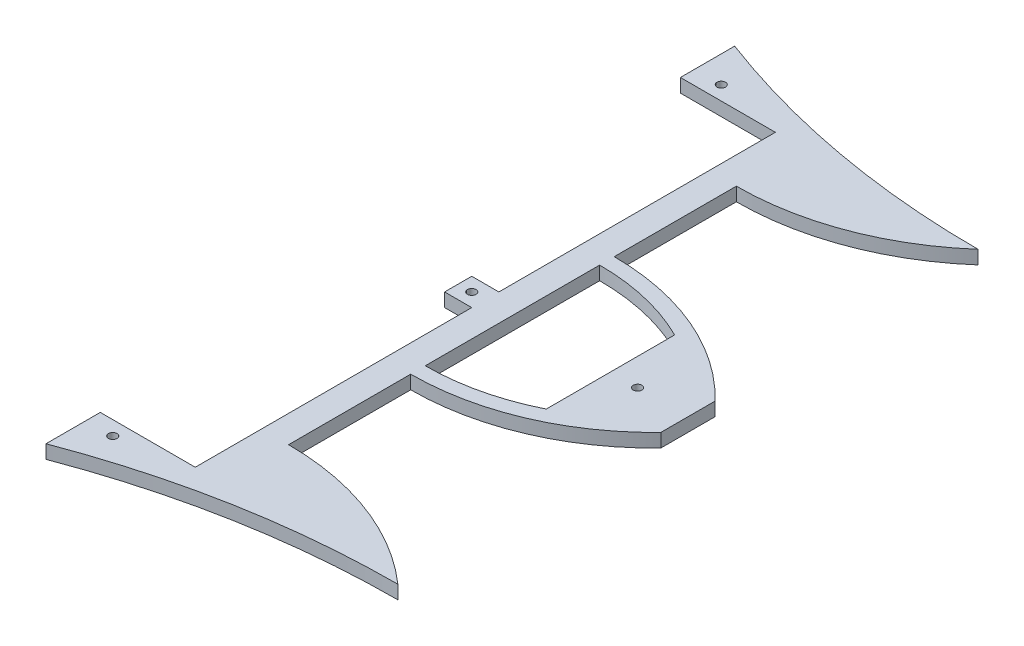
from build123d import *

# Parameters (mm, degrees)
BOSS_EXTRUDE3_DEPTH = 6.35
SKETCH2_R           = 2
CUT_EXTRUDE1_DEPTH  = 6.35
SKETCH3_W           = 44.45
SKETCH3_H           = 34.144934764
CUT_EXTRUDE2_DEPTH  = 6.35
BOSS_EXTRUDE5_DEPTH = 6.35
CUT_EXTRUDE3_DEPTH  = 6.35
CUT_EXTRUDE4_DEPTH  = 6.35
SKETCH8_R           = 2
CUT_EXTRUDE5_DEPTH  = 6.35


with BuildPart() as part:
    # Sketch1 → Boss-Extrude3 (new body)
    with BuildSketch(Plane(origin=(0, 0, 0), x_dir=(1, 0, 0), z_dir=(0, 1, 0))):
        with BuildLine():
            ThreePointArc((101.6, -161.144934764), (118.310930869, -149.307647617), (133.654639598, -135.744934764))
            Line((133.654639598, -135.744934764), (124.436872293, -135.744934764))
            Line((124.436872293, -135.744934764), (101.6, -135.744934764))
            Line((101.6, -135.744934764), (101.6, -161.144934764))
        make_face()
        with BuildLine():
            Line((146.05, -112.163363002), (146.05, -101.6))
            Line((146.05, -101.6), (101.6, -101.6))
            Line((101.6, -101.6), (101.6, -135.744934764))
            Line((101.6, -135.744934764), (124.436872293, -135.744934764))
            ThreePointArc((124.436872293, -135.744934764), (135.756435031, -124.424325787), (146.05, -112.163363002))
        make_face()
        with BuildLine():
            Line((152.4, -76.2), (152.4, -101.6))
            Line((152.4, -101.6), (157.687433266, -106.887433266))
            ThreePointArc((157.687433266, -106.887433266), (155.08800922, -110.62531083), (152.4, -114.3))
            ThreePointArc((152.4, -114.3), (143.428677452, -125.373300524), (133.654639598, -135.744934764))
            Line((133.654639598, -135.744934764), (190.5, -135.744934764))
            Line((190.5, -135.744934764), (240.876195248, -135.744934764))
            ThreePointArc((240.876195248, -135.744934764), (203.220744642, -110.47631512), (158.75, -101.6))
            Line((158.75, -101.6), (158.75, -76.2))
            Line((158.75, -76.2), (152.4, -76.2))
        make_face()
        with BuildLine():
            Line((146.05, -76.2), (152.4, -76.2))
            Line((152.4, -76.2), (152.4, -50.8))
            Line((152.4, -50.8), (190.076195248, -12.7))
            ThreePointArc((190.076195248, -12.7), (190.5, 0), (190.076195248, 12.7))
            Line((190.076195248, 12.7), (152.4, 50.8))
            Line((152.4, 50.8), (152.4, 76.2))
            Line((152.4, 76.2), (146.05, 76.2))
            Line((146.05, 76.2), (146.05, 6.35))
            Line((146.05, 6.35), (133.35, 6.35))
            Line((133.35, 6.35), (133.35, -6.35))
            Line((133.35, -6.35), (146.05, -6.35))
            Line((146.05, -6.35), (146.05, -76.2))
        make_face()
        with BuildLine():
            Line((157.687433266, -106.887433266), (152.4, -101.6))
            Line((152.4, -101.6), (152.4, -76.2))
            Line((152.4, -76.2), (146.05, -76.2))
            Line((146.05, -76.2), (146.05, -101.6))
            Line((146.05, -101.6), (146.05, -112.163363002))
            ThreePointArc((146.05, -112.163363002), (135.756435031, -124.424325787), (124.436872293, -135.744934764))
            Line((124.436872293, -135.744934764), (133.654639598, -135.744934764))
            ThreePointArc((133.654639598, -135.744934764), (143.428677452, -125.373300524), (152.4, -114.3))
            ThreePointArc((152.4, -114.3), (155.08800922, -110.62531083), (157.687433266, -106.887433266))
        make_face()
        with BuildLine():
            Line((101.6, 101.6), (146.05, 101.6))
            Line((146.05, 101.6), (146.05, 112.163363002))
            ThreePointArc((146.05, 112.163363002), (135.756435031, 124.424325787), (124.436872293, 135.744934764))
            Line((124.436872293, 135.744934764), (101.6, 135.744934764))
            Line((101.6, 135.744934764), (101.6, 101.6))
        make_face()
        with BuildLine():
            Line((124.436872293, 135.744934764), (133.654639598, 135.744934764))
            ThreePointArc((133.654639598, 135.744934764), (118.310930869, 149.307647617), (101.6, 161.144934764))
            Line((101.6, 161.144934764), (101.6, 135.744934764))
            Line((101.6, 135.744934764), (124.436872293, 135.744934764))
        make_face()
        with BuildLine():
            Line((146.05, 76.2), (152.4, 76.2))
            Line((152.4, 76.2), (152.4, 101.6))
            Line((152.4, 101.6), (157.687433266, 106.887433266))
            ThreePointArc((157.687433266, 106.887433266), (155.08800922, 110.62531083), (152.4, 114.3))
            ThreePointArc((152.4, 114.3), (143.428677452, 125.373300524), (133.654639598, 135.744934764))
            Line((133.654639598, 135.744934764), (124.436872293, 135.744934764))
            ThreePointArc((124.436872293, 135.744934764), (135.756435031, 124.424325787), (146.05, 112.163363002))
            Line((146.05, 112.163363002), (146.05, 101.6))
            Line((146.05, 101.6), (146.05, 76.2))
        make_face()
        with BuildLine():
            Line((152.4, 50.8), (190.076195248, 12.7))
            Line((190.076195248, 12.7), (240.876195248, 12.7))
            ThreePointArc((240.876195248, 12.7), (204.016770224, 40.811197813), (158.75, 50.8))
            Line((158.75, 50.8), (158.75, 76.2))
            Line((158.75, 76.2), (152.4, 76.2))
            Line((152.4, 76.2), (152.4, 50.8))
        make_face()
        with BuildLine():
            Line((152.4, -50.8), (152.4, -76.2))
            Line((152.4, -76.2), (158.75, -76.2))
            Line((158.75, -76.2), (158.75, -50.8))
            ThreePointArc((158.75, -50.8), (204.016770224, -40.811197813), (240.876195248, -12.7))
            Line((240.876195248, -12.7), (190.076195248, -12.7))
            Line((190.076195248, -12.7), (152.4, -50.8))
        make_face()
        with BuildLine():
            ThreePointArc((190.076195248, -12.7), (190.5, 0), (190.076195248, 12.7))
            Line((190.076195248, 12.7), (240.876195248, 12.7))
            Line((240.876195248, 12.7), (240.876195248, -12.7))
            Line((240.876195248, -12.7), (190.076195248, -12.7))
        make_face()
        with BuildLine():
            ThreePointArc((158.75, 101.6), (203.220744642, 110.47631512), (240.876195248, 135.744934764))
            Line((240.876195248, 135.744934764), (190.5, 135.744934764))
            Line((190.5, 135.744934764), (133.654639598, 135.744934764))
            ThreePointArc((133.654639598, 135.744934764), (143.428677452, 125.373300524), (152.4, 114.3))
            ThreePointArc((152.4, 114.3), (155.08800922, 110.62531083), (157.687433266, 106.887433266))
            Line((157.687433266, 106.887433266), (152.4, 101.6))
            Line((152.4, 101.6), (152.4, 76.2))
            Line((152.4, 76.2), (158.75, 76.2))
            Line((158.75, 76.2), (158.75, 101.6))
        make_face()
    extrude(amount=BOSS_EXTRUDE3_DEPTH)

    # Sketch2 → Cut-Extrude1 (cut)
    with BuildSketch(Plane(origin=(0, 6.35, 0), x_dir=(1, 0, 0), z_dir=(0, 1, 0))):
        with Locations((139.7, 0)):
            Circle(SKETCH2_R)
        with Locations((114.080664861, 142.381475953)):
            Circle(SKETCH2_R)
        with Locations((114.080664861, -142.381475953)):
            Circle(SKETCH2_R)
    extrude(amount=-CUT_EXTRUDE1_DEPTH, mode=Mode.SUBTRACT)

    # Sketch3 → Cut-Extrude2 (cut)
    with BuildSketch(Plane(origin=(0, 6.35, 0), x_dir=(1, 0, 0), z_dir=(0, 1, 0))):
        with Locations((123.825, 118.672467382)):
            Rectangle(SKETCH3_W, SKETCH3_H)
        with Locations((123.825, -118.672467382)):
            Rectangle(SKETCH3_W, SKETCH3_H)
    extrude(amount=-CUT_EXTRUDE2_DEPTH, mode=Mode.SUBTRACT)

    # Sketch4 → Boss-Extrude5 (add)
    with BuildSketch(Plane(origin=(0, 6.35, 0), x_dir=(1, 0, 0), z_dir=(0, 1, 0))):
        with BuildLine():
            Line((146.05, 135.744934764), (240.876195248, 135.744934764))
            ThreePointArc((240.876195248, 135.744934764), (170.089511185, 142.146873772), (101.6, 161.144934764))
            Line((101.6, 161.144934764), (133.654639598, 135.744934764))
            Line((133.654639598, 135.744934764), (146.05, 135.744934764))
        make_face()
        with BuildLine():
            ThreePointArc((101.6, -161.144934764), (170.089511185, -142.146873772), (240.876195248, -135.744934764))
            Line((240.876195248, -135.744934764), (146.05, -135.744934764))
            Line((146.05, -135.744934764), (133.654639598, -135.744934764))
            Line((133.654639598, -135.744934764), (101.6, -161.144934764))
        make_face()
    extrude(amount=-BOSS_EXTRUDE5_DEPTH)

    # Sketch6 → Cut-Extrude3 (cut)
    with BuildSketch(Plane(origin=(0, 6.35, 0), x_dir=(1, 0, 0), z_dir=(0, 1, 0))):
        with BuildLine():
            ThreePointArc((204.6037507, 30.046043954), (182.300238804, 38.083813069), (158.75, 40.811197813))
            Line((158.75, 40.811197813), (158.75, -40.811197813))
            ThreePointArc((158.75, -40.811197813), (182.300238804, -38.083813069), (204.6037507, -30.046043954))
            Line((204.6037507, -30.046043954), (204.6037507, 30.046043954))
        make_face()
    extrude(amount=-CUT_EXTRUDE3_DEPTH, mode=Mode.SUBTRACT)

    # Sketch7 → Cut-Extrude4 (cut)
    with BuildSketch(Plane(origin=(0, 6.35, 0), x_dir=(1, 0, 0), z_dir=(0, 1, 0))):
        with BuildLine():
            ThreePointArc((158.75, 104.775), (202.635785869, 112.774751554), (240.876195248, 135.744934764))
            ThreePointArc((240.876195248, 135.744934764), (203.220744642, 110.47631512), (158.75, 101.6))
            Line((158.75, 101.6), (158.75, 104.775))
        make_face()
        with BuildLine():
            Line((158.75, 50.8), (158.75, 47.625))
            ThreePointArc((158.75, 47.625), (203.371932866, 38.531106957), (240.876195248, 12.7))
            ThreePointArc((240.876195248, 12.7), (204.016770224, 40.811197813), (158.75, 50.8))
        make_face()
        with BuildLine():
            ThreePointArc((158.75, -47.625), (203.371932866, -38.531106957), (240.876195248, -12.7))
            ThreePointArc((240.876195248, -12.7), (204.016770224, -40.811197813), (158.75, -50.8))
            Line((158.75, -50.8), (158.75, -47.625))
        make_face()
        with BuildLine():
            Line((158.75, -104.775), (158.75, -101.6))
            ThreePointArc((158.75, -101.6), (203.220744642, -110.47631512), (240.876195248, -135.744934764))
            ThreePointArc((240.876195248, -135.744934764), (202.635785869, -112.774751554), (158.75, -104.775))
        make_face()
    extrude(amount=-CUT_EXTRUDE4_DEPTH, mode=Mode.SUBTRACT)

    # Sketch8 → Cut-Extrude5 (cut)
    with BuildSketch(Plane(origin=(0, 6.35, 0), x_dir=(1, 0, 0), z_dir=(0, 1, 0))):
        with Locations((217.3037507, 0)):
            Circle(SKETCH8_R)
    extrude(amount=-CUT_EXTRUDE5_DEPTH, mode=Mode.SUBTRACT)


solid = part.part
